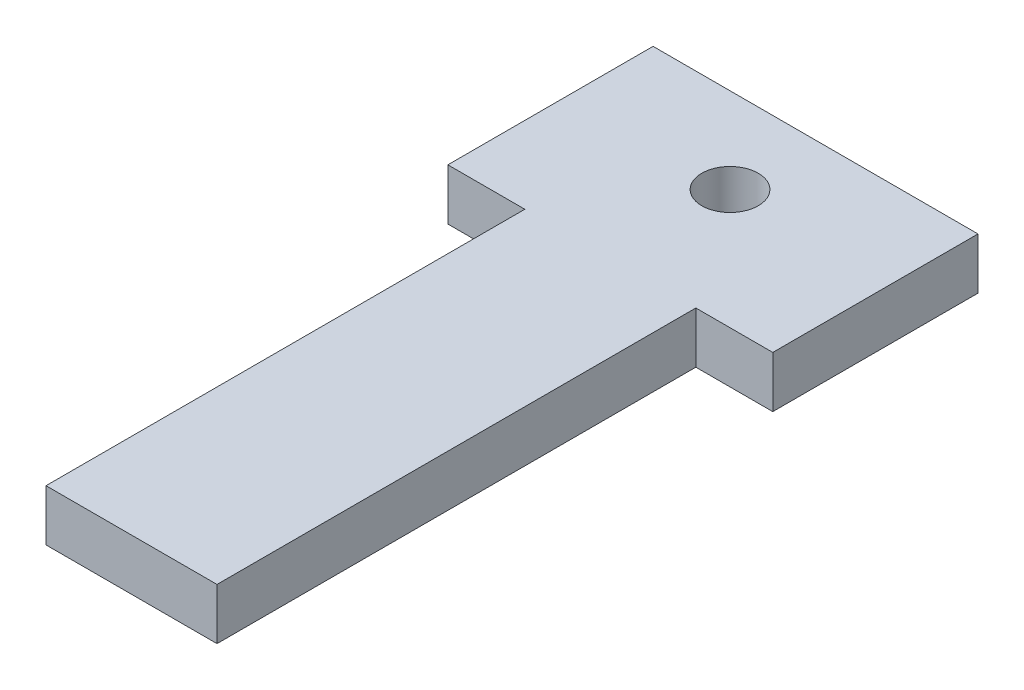
from build123d import *

# Parameters (mm, degrees)
SKETCH1_W           = 10
SKETCH1_H           = 40
SKETCH1_R           = 1.65
SKETCH1_W_2         = 4.5
SKETCH1_H_2         = 12
BOSS_EXTRUDE1_DEPTH = 3


with BuildPart() as part:
    # Sketch1 → Boss-Extrude1 (new body)
    with BuildSketch(Plane(origin=(0, 0, 0), x_dir=(1, 0, 0), z_dir=(0, 1, 0))):
        with Locations((0, -15)):
            Rectangle(SKETCH1_W, SKETCH1_H)
        Circle(SKETCH1_R, mode=Mode.SUBTRACT)
        with Locations((-7.25, -1)):
            Rectangle(SKETCH1_W_2, SKETCH1_H_2)
        with Locations((7.25, -1)):
            Rectangle(SKETCH1_W_2, SKETCH1_H_2)
    extrude(amount=BOSS_EXTRUDE1_DEPTH)


solid = part.part
